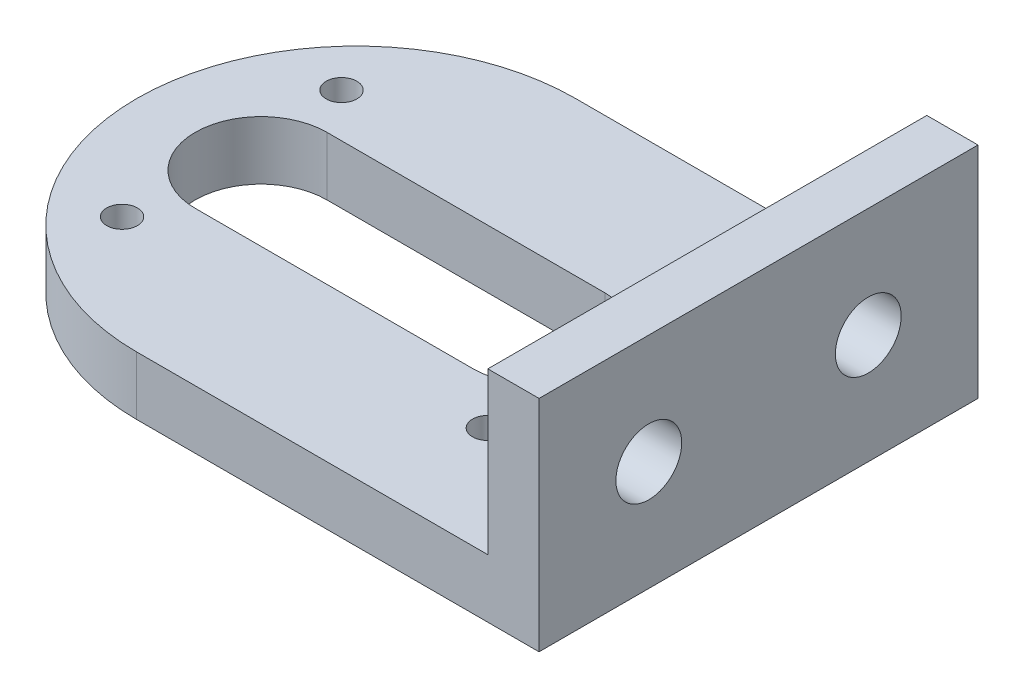
from build123d import *

# Parameters (mm, degrees)
EXTRUDE_1_DEPTH     = 8
SKETCH_2_W          = 7
SKETCH_2_H          = 60
EXTRUDE_2_DEPTH     = 22
MM_1_D              = 9
CUT_EXTRUDE_1_DEPTH = 22
HOLE_WIZARD_M5_1_D  = 4.2


with BuildPart() as part:
    # 草图1 → 凸台-拉伸1 (new body)
    with BuildSketch(Plane(origin=(0, 0, 0), x_dir=(1, 0, 0), z_dir=(0, 1, 0))):
        with BuildLine():
            Line((-14.75, 30), (40.25, 30))
            Line((40.25, 30), (40.25, -30))
            Line((40.25, -30), (-14.75, -30))
            ThreePointArc((-14.75, -30), (-44.75, 0), (-14.75, 30))
        make_face()
    extrude(amount=EXTRUDE_1_DEPTH)

    # 草图2 → 凸台-拉伸2 (add)
    with BuildSketch(Plane(origin=(0, 8, 0), x_dir=(1, 0, 0), z_dir=(0, 1, 0))):
        with Locations((36.75, 0)):
            Rectangle(SKETCH_2_W, SKETCH_2_H)
    extrude(amount=EXTRUDE_2_DEPTH)

    # 大小mm 暗销孔1 (through all)
    with Locations(Plane(origin=(40.25, 15, 15), x_dir=(0, 0, 1), z_dir=(1, 0, 0))):
        with Locations((0, 0), (-30, 0)):
            Hole(MM_1_D / 2)

    # 草图5 → 切除-拉伸1 (cut)
    with BuildSketch(Plane.XZ):
        with BuildLine():
            Line((-27.75, 9), (10.25, 9))
            ThreePointArc((10.25, 9), (19.25, 0), (10.25, -9))
            Line((10.25, -9), (-27.75, -9))
            ThreePointArc((-27.75, -9), (-36.75, 0), (-27.75, 9))
        make_face()
    extrude(amount=-CUT_EXTRUDE_1_DEPTH, mode=Mode.SUBTRACT)

    # M5 螺纹孔1 (through all)
    with Locations(Plane(origin=(-31.75, 0, 15), x_dir=(0, 0, -1), z_dir=(0, -1, 0))):
        with Locations((0, 0), (0, 50), (30, 50), (30, 0)):
            Hole(HOLE_WIZARD_M5_1_D / 2)


solid = part.part
